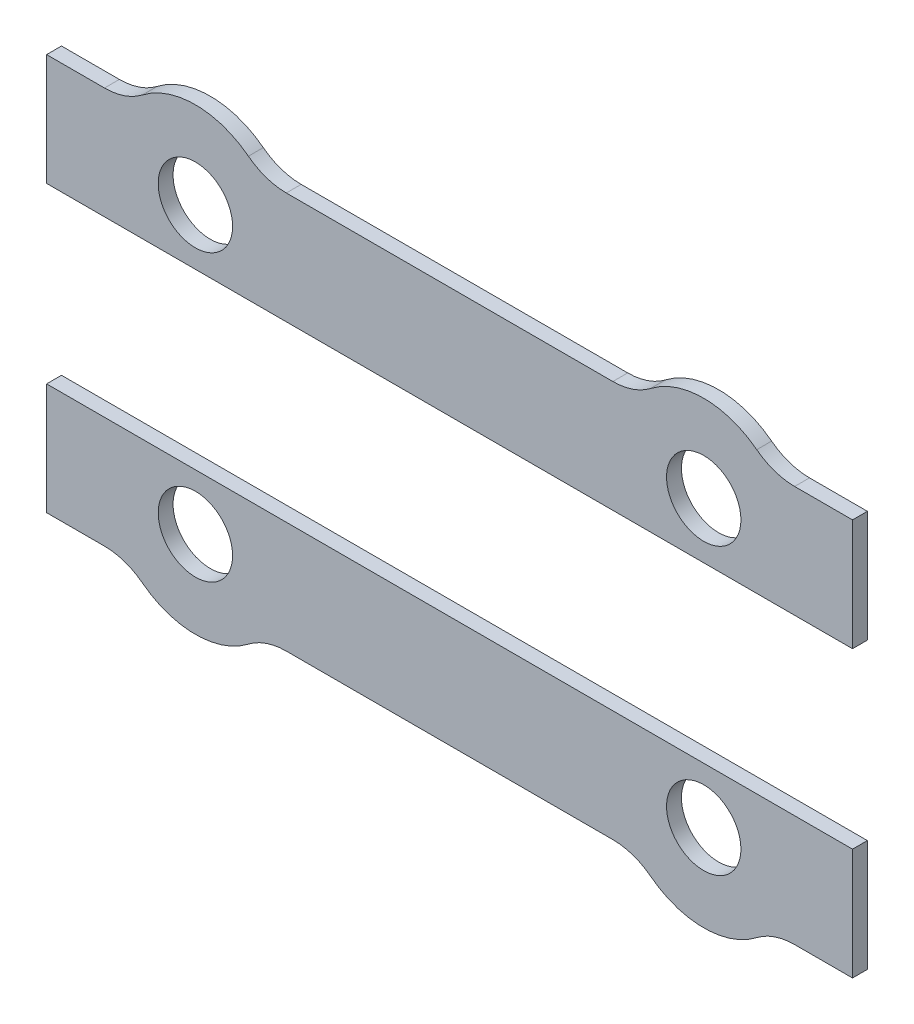
from build123d import *

# Parameters (mm, degrees)
SKETCH1_R           = 1.5
BOSS_EXTRUDE1_DEPTH = 0.6


with BuildPart() as part:
    # Sketch1 → Boss-Extrude1 (new body)
    with BuildSketch(Plane(origin=(0, 14.6, 0), x_dir=(1, 0, 0), z_dir=(0, 0, 1))):
        with BuildLine():
            Line((0, 1.4), (0, -3.1))
            Line((0, -3.1), (16.250000005, -3.1))
            Line((16.250000005, -3.1), (16.250000005, 1.4))
            Line((16.250000005, 1.4), (9.665719575, 1.4))
            ThreePointArc((9.665719575, 1.4), (9.256775524, 1.433673833), (8.858848044, 1.533788189))
            ThreePointArc((8.858848044, 1.533788189), (8.48265693, 1.697646082), (8.138336419, 1.920833333))
            ThreePointArc((8.138336419, 1.920833333), (6.502278947, 2.613771912), (4.736783251, 2.414089987))
            ThreePointArc((4.736783251, 2.414089987), (4.28143475, 2.199021725), (3.861663581, 1.920833333))
            ThreePointArc((3.861663581, 1.920833333), (3.174687447, 1.545490277), (2.405308582, 1.401009204))
            ThreePointArc((2.405308582, 1.401009204), (2.369798088, 1.400252314), (2.334280425, 1.4))
            Line((2.334280425, 1.4), (0, 1.4))
        make_face()
        with Locations((6, -0.85)):
            Circle(SKETCH1_R, mode=Mode.SUBTRACT)
        with BuildLine():
            Line((16.250000005, -10.1), (0, -10.1))
            Line((0, -10.1), (0, -14.6))
            Line((0, -14.6), (2.334280425, -14.6))
            ThreePointArc((2.334280425, -14.6), (2.369798088, -14.600252314), (2.405308582, -14.601009204))
            ThreePointArc((2.405308582, -14.601009204), (3.174687447, -14.745490277), (3.861663581, -15.120833333))
            ThreePointArc((3.861663581, -15.120833333), (4.28143475, -15.399021725), (4.736783251, -15.614089987))
            ThreePointArc((4.736783251, -15.614089987), (6.502278947, -15.813771912), (8.138336419, -15.120833333))
            ThreePointArc((8.138336419, -15.120833333), (8.48265693, -14.897646082), (8.858848044, -14.733788189))
            ThreePointArc((8.858848044, -14.733788189), (9.256775524, -14.633673833), (9.665719575, -14.6))
            Line((9.665719575, -14.6), (16.250000005, -14.6))
            Line((16.250000005, -14.6), (16.250000005, -10.1))
        make_face()
        with Locations((6, -12.35)):
            Circle(SKETCH1_R, mode=Mode.SUBTRACT)
        with BuildLine():
            Line((16.250000005, 1.4), (16.250000005, -3.1))
            Line((16.250000005, -3.1), (32.500000009, -3.1))
            Line((32.500000009, -3.1), (32.500000009, 1.4))
            Line((32.500000009, 1.4), (30.165719584, 1.4))
            ThreePointArc((30.165719584, 1.4), (30.130201921, 1.400252314), (30.094691427, 1.401009204))
            ThreePointArc((30.094691427, 1.401009204), (29.325312562, 1.545490277), (28.638336428, 1.920833333))
            ThreePointArc((28.638336428, 1.920833333), (28.21856526, 2.199021725), (27.763216759, 2.414089987))
            ThreePointArc((27.763216759, 2.414089987), (25.997721062, 2.613771912), (24.361663591, 1.920833333))
            ThreePointArc((24.361663591, 1.920833333), (24.017343079, 1.697646082), (23.641151965, 1.533788189))
            ThreePointArc((23.641151965, 1.533788189), (23.243224485, 1.433673833), (22.834280435, 1.4))
            Line((22.834280435, 1.4), (16.250000005, 1.4))
        make_face()
        with Locations((26.500000009, -0.85)):
            Circle(SKETCH1_R, mode=Mode.SUBTRACT)
        with BuildLine():
            Line((32.500000009, -10.1), (16.250000005, -10.1))
            Line((16.250000005, -10.1), (16.250000005, -14.6))
            Line((16.250000005, -14.6), (22.834280435, -14.6))
            ThreePointArc((22.834280435, -14.6), (23.243224485, -14.633673833), (23.641151965, -14.733788189))
            ThreePointArc((23.641151965, -14.733788189), (24.017343079, -14.897646082), (24.361663591, -15.120833333))
            ThreePointArc((24.361663591, -15.120833333), (25.997721062, -15.813771912), (27.763216759, -15.614089987))
            ThreePointArc((27.763216759, -15.614089987), (28.21856526, -15.399021725), (28.638336428, -15.120833333))
            ThreePointArc((28.638336428, -15.120833333), (29.325312562, -14.745490277), (30.094691427, -14.601009204))
            ThreePointArc((30.094691427, -14.601009204), (30.130201921, -14.600252314), (30.165719584, -14.6))
            Line((30.165719584, -14.6), (32.500000009, -14.6))
            Line((32.500000009, -14.6), (32.500000009, -10.1))
        make_face()
        with Locations((26.500000009, -12.35)):
            Circle(SKETCH1_R, mode=Mode.SUBTRACT)
    extrude(amount=BOSS_EXTRUDE1_DEPTH)


solid = part.part
